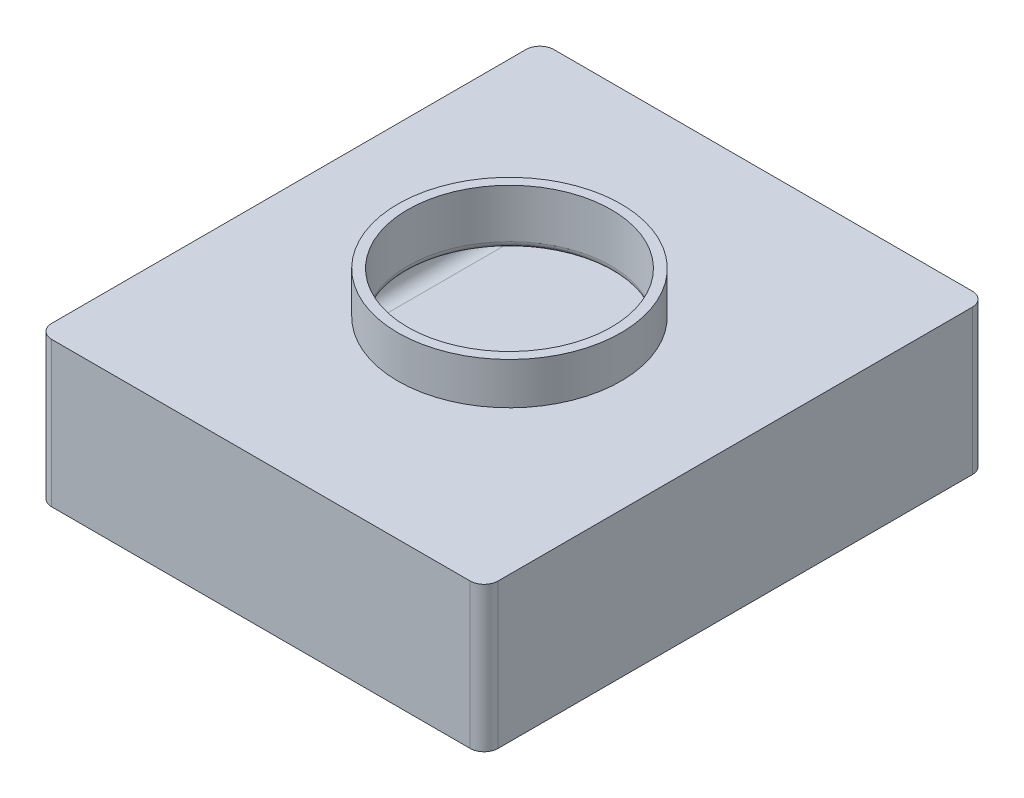
from build123d import *

# Parameters (mm, degrees)
SKETCH1_W           = 203.2
SKETCH1_H           = 228.6
SKETCH1_W_2         = 190.5
SKETCH1_H_2         = 215.9
BOSS_EXTRUDE1_DEPTH = 53.34
SKETCH2_W           = 203.2
SKETCH2_H           = 228.6
BOSS_EXTRUDE2_DEPTH = 6.35
SKETCH3_W           = 203.2
SKETCH3_H           = 228.6
BOSS_EXTRUDE3_DEPTH = 6.35
CUT_EXTRUDE1_REACH  = 68.04
SKETCH5_R           = 46.355
FILLET5_R           = 6.35
SKETCH6_R           = 50.8
SKETCH6_R_2         = 46.355
BOSS_EXTRUDE4_DEPTH = 19.05
FILLET6_R           = 3.175


with BuildPart() as part:
    # Sketch1 → Boss-Extrude1 (new body)
    with BuildSketch(Plane(origin=(0, 0, 0), x_dir=(1, 0, 0), z_dir=(0, 1, 0))):
        with Locations((-54.462846348, 15.85288386)):
            Rectangle(SKETCH1_W, SKETCH1_H)
        with Locations((-54.462846348, 15.85288386)):
            Rectangle(SKETCH1_W_2, SKETCH1_H_2, mode=Mode.SUBTRACT)
    extrude(amount=BOSS_EXTRUDE1_DEPTH)

    # Sketch2 → Boss-Extrude2 (add)
    with BuildSketch(Plane(origin=(0, 0, 0), x_dir=(-1, 0, 0), z_dir=(0, -1, 0))):
        with Locations((54.462846348, 15.85288386)):
            Rectangle(SKETCH2_W, SKETCH2_H)
    extrude(amount=BOSS_EXTRUDE2_DEPTH)

    # Sketch3 → Boss-Extrude3 (add)
    with BuildSketch(Plane(origin=(0, 53.34, 0), x_dir=(1, 0, 0), z_dir=(0, 1, 0))):
        with Locations((-54.462846348, 15.85288386)):
            Rectangle(SKETCH3_W, SKETCH3_H)
    extrude(amount=BOSS_EXTRUDE3_DEPTH)

    # Sketch5 → Cut-Extrude1 (cut, up to next)
    with BuildSketch(Plane(origin=(0, 59.69, 0), x_dir=(1, 0, 0), z_dir=(0, 1, 0)), mode=Mode.PRIVATE) as cut_extrude1_sk1:
        with Locations((-54.462846348, 14.706120018)):
            Circle(SKETCH5_R)
    cut_extrude1_tool1 = extrude(cut_extrude1_sk1.sketch, amount=-CUT_EXTRUDE1_REACH, mode=Mode.PRIVATE) & part.part
    add(cut_extrude1_tool1.solids().sort_by_distance((-54.462846, 59.69, -14.70612))[0], mode=Mode.SUBTRACT)

    # Fillet5
    fillet5_edges = [part.edges().sort_by_distance(p)[0] for p in [
        (-149.712846348, 0, -15.85288386),
        (-149.712846348, 26.67, -123.80288386),
        (-54.462846348, 0, 92.09711614),
        (-149.712846348, 26.67, 92.09711614),
        (40.787153652, 0, -15.85288386),
        (40.787153652, 26.67, 92.09711614),
        (-54.462846348, 0, -123.80288386),
        (40.787153652, 26.67, -123.80288386),
        (-149.712846348, 53.34, -15.85288386),
        (-54.462846348, 53.34, 92.09711614),
        (40.787153652, 53.34, -15.85288386),
        (-54.462846348, 53.34, -123.80288386),
        (-156.062846348, 26.67, -130.15288386),
        (47.137153652, 26.67, -130.15288386),
        (47.137153652, 26.67, 98.44711614),
        (-156.062846348, 26.67, 98.44711614),
    ]]
    fillet(fillet5_edges, radius=FILLET5_R)

    # Sketch6 → Boss-Extrude4 (add)
    with BuildSketch(Plane(origin=(0, 59.69, 0), x_dir=(1, 0, 0), z_dir=(0, 1, 0))):
        with Locations((-54.462846348, 14.706120018)):
            Circle(SKETCH6_R)
        with Locations((-54.462846348, 14.706120018)):
            Circle(SKETCH6_R_2, mode=Mode.SUBTRACT)
    extrude(amount=BOSS_EXTRUDE4_DEPTH)

    # Fillet6
    fillet6_edges = [part.edges().sort_by_distance(p)[0] for p in [
        (-100.817846348, 53.34, -14.706120018),
    ]]
    fillet(fillet6_edges, radius=FILLET6_R)


solid = part.part
